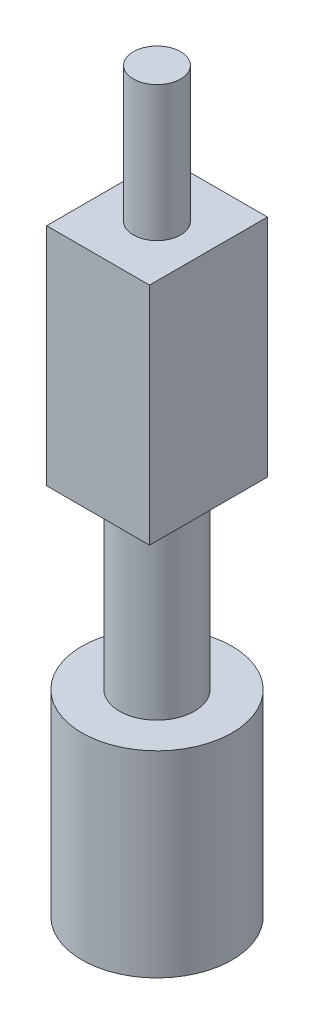
from build123d import *

# Parameters (mm, degrees)
SKETCH1_W           = 13.7
SKETCH1_H           = 15.7
BOSS_EXTRUDE1_DEPTH = 30
SKETCH2_R           = 5
BOSS_EXTRUDE2_DEPTH = 24
SKETCH3_R           = 10
BOSS_EXTRUDE3_DEPTH = 26.2
SKETCH4_R           = 5
BOSS_EXTRUDE4_DEPTH = 3
SKETCH5_R           = 3.15
BOSS_EXTRUDE5_DEPTH = 18
SKETCH8_R           = 1.5
CUT_EXTRUDE1_DEPTH  = 2


with BuildPart() as part:
    # Sketch1 → Boss-Extrude1 (new body)
    with BuildSketch(Plane(origin=(0, 0, 0), x_dir=(1, 0, 0), z_dir=(0, 1, 0))):
        Rectangle(SKETCH1_W, SKETCH1_H)
    extrude(amount=BOSS_EXTRUDE1_DEPTH)

    # Sketch2 → Boss-Extrude2 (add)
    with BuildSketch(Plane.XZ):
        Circle(SKETCH2_R)
    extrude(amount=BOSS_EXTRUDE2_DEPTH)

    # Sketch3 → Boss-Extrude3 (add)
    with BuildSketch(Plane.XZ.offset(24)):
        Circle(SKETCH3_R)
    extrude(amount=BOSS_EXTRUDE3_DEPTH)

    # Sketch4 → Boss-Extrude4 (add)
    with BuildSketch(Plane.XZ.offset(50.2)):
        Circle(SKETCH4_R)
    extrude(amount=BOSS_EXTRUDE4_DEPTH)

    # Sketch5 → Boss-Extrude5 (add)
    with BuildSketch(Plane(origin=(0, 30, 0), x_dir=(1, 0, 0), z_dir=(0, 1, 0))):
        Circle(SKETCH5_R)
    extrude(amount=BOSS_EXTRUDE5_DEPTH)

    # Sketch8 → Cut-Extrude1 (cut)
    with BuildSketch(Plane(origin=(0, 0, -7.85), x_dir=(-1, 0, 0), z_dir=(0, 0, -1))):
        with Locations((0, 8)):
            Circle(SKETCH8_R)
        with Locations((0, 22.8)):
            Circle(SKETCH8_R)
    extrude(amount=-CUT_EXTRUDE1_DEPTH, mode=Mode.SUBTRACT)


solid = part.part
